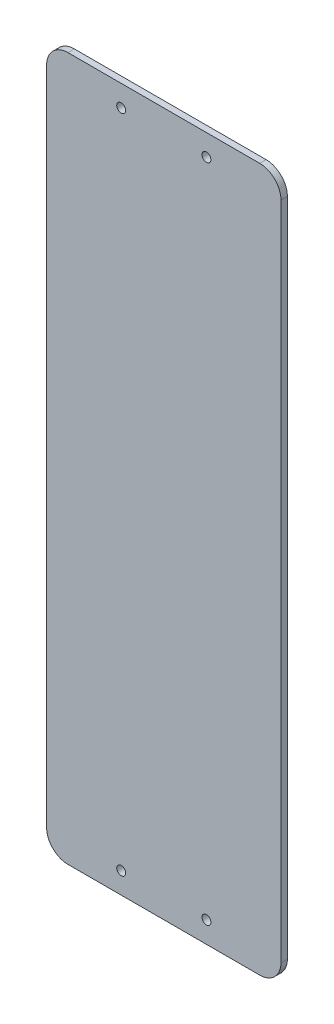
from build123d import *

# Parameters (mm, degrees)
SKETCH1_W           = 110
SKETCH1_H           = 330
SKETCH1_R           = 2.1
BOSS_EXTRUDE1_DEPTH = 3
FILLET1_R           = 10


with BuildPart() as part:
    # Sketch1 → Boss-Extrude1 (new body)
    with BuildSketch(Plane.XY):
        with Locations((55, 165)):
            Rectangle(SKETCH1_W, SKETCH1_H)
        with Locations((35, 320)):
            Circle(SKETCH1_R, mode=Mode.SUBTRACT)
        with Locations((75, 320)):
            Circle(SKETCH1_R, mode=Mode.SUBTRACT)
        with Locations((75, 10)):
            Circle(SKETCH1_R, mode=Mode.SUBTRACT)
        with Locations((35, 10)):
            Circle(SKETCH1_R, mode=Mode.SUBTRACT)
    extrude(amount=BOSS_EXTRUDE1_DEPTH)

    # Fillet1
    fillet1_edges = [part.edges().sort_by_distance(p)[0] for p in [
        (0, 330, 1.5),
        (110, 330, 1.5),
        (110, 0, 1.5),
        (0, 0, 1.5),
    ]]
    fillet(fillet1_edges, radius=FILLET1_R)


solid = part.part
